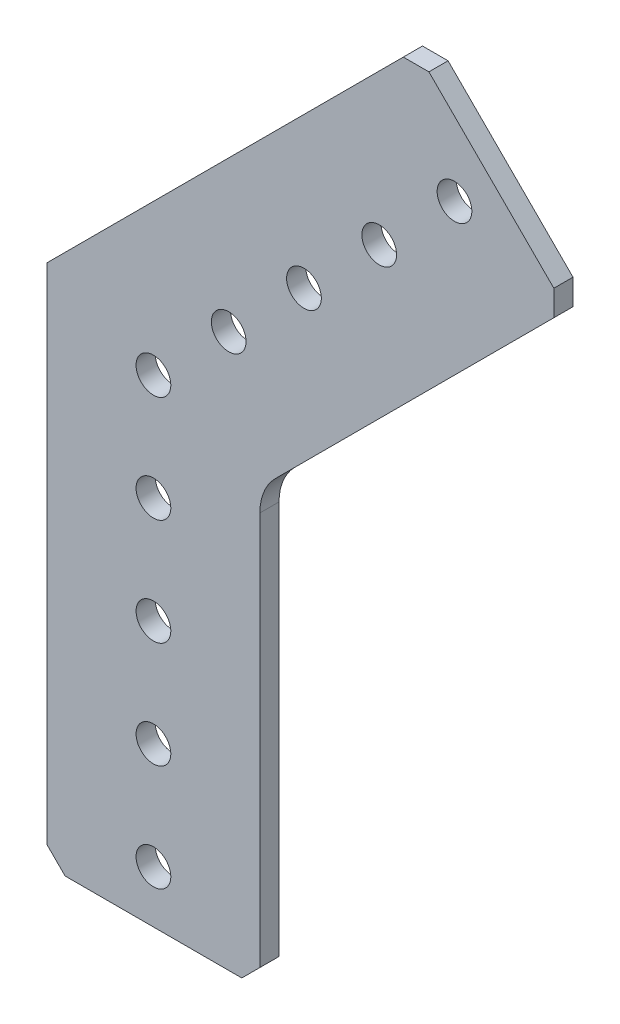
from build123d import *

# Parameters (mm, degrees)
SKETCH1_R           = 2.0701
BOSS_EXTRUDE1_DEPTH = 2.286


with BuildPart() as part:
    # Sketch1 → Boss-Extrude1 (new body)
    with BuildSketch(Plane.XY.offset(2.286)):
        with BuildLine():
            Line((32.867737403, 47.774962564), (29.814450322, 47.774962564))
            Line((29.814450322, 47.774962564), (-12.7, 5.260512242))
            Line((-12.7, 5.260512242), (-12.7, -54.864))
            Line((-12.7, -54.864), (-10.541, -57.023))
            Line((-10.541, -57.023), (10.541, -57.023))
            Line((10.541, -57.023), (12.7, -54.864))
            Line((12.7, -54.864), (12.7, -7.890768363))
            ThreePointArc((12.7, -7.890768363), (13.183364969, -5.460728568), (14.559871939, -3.400640303))
            Line((14.559871939, -3.400640303), (47.774962564, 29.814450322))
            Line((47.774962564, 29.814450322), (47.774962564, 32.867737403))
            Line((47.774962564, 32.867737403), (32.867737403, 47.774962564))
        make_face()
        with Locations((35.921024484, 35.921024484)):
            Circle(SKETCH1_R, mode=Mode.SUBTRACT)
        with Locations((17.960512242, 17.960512242)):
            Circle(SKETCH1_R, mode=Mode.SUBTRACT)
        with Locations((8.980256121, 8.980256121)):
            Circle(SKETCH1_R, mode=Mode.SUBTRACT)
        with Locations((26.940768363, 26.940768363)):
            Circle(SKETCH1_R, mode=Mode.SUBTRACT)
        with Locations((0, -50.8)):
            Circle(SKETCH1_R, mode=Mode.SUBTRACT)
        with Locations((0, -25.4)):
            Circle(SKETCH1_R, mode=Mode.SUBTRACT)
        with Locations((0, -12.7)):
            Circle(SKETCH1_R, mode=Mode.SUBTRACT)
        with Locations((0, -38.1)):
            Circle(SKETCH1_R, mode=Mode.SUBTRACT)
        Circle(SKETCH1_R, mode=Mode.SUBTRACT)
    extrude(amount=-BOSS_EXTRUDE1_DEPTH)


solid = part.part
